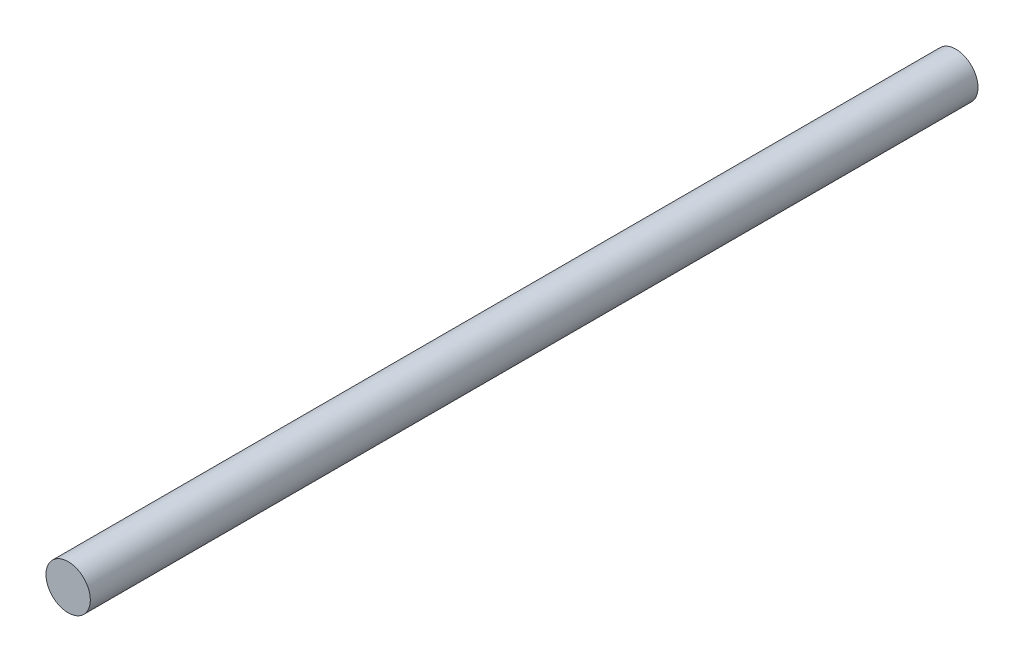
from build123d import *

# Parameters (mm, degrees)
SKETCH2_R           = 10
BOSS_EXTRUDE1_DEPTH = 200


with BuildPart() as part:
    # Sketch2 → Boss-Extrude1 (new body, symmetric)
    with BuildSketch(Plane.XY):
        Circle(SKETCH2_R)
    extrude(amount=BOSS_EXTRUDE1_DEPTH, both=True)


solid = part.part
